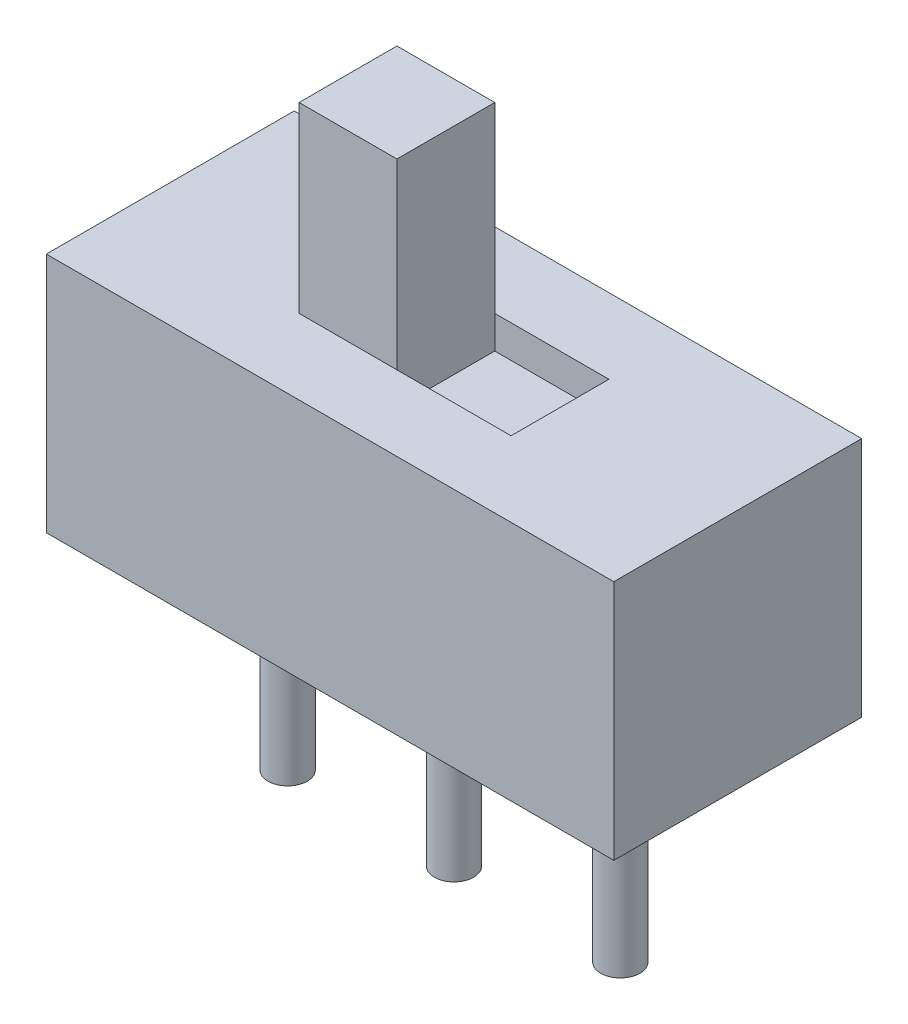
from build123d import *

# Parameters (mm, degrees)
ESQUISSE1_W             = 8.7
ESQUISSE1_H             = 3.7
BOSS_EXTRU_1_DEPTH      = 3.8
ESQUISSE2_W             = 3.25
ESQUISSE2_H             = 1.5
ENL_V_MAT_EXTRU_1_DEPTH = 0.5
ESQUISSE3_W             = 1.5
ESQUISSE3_H             = 1.5
BOSS_EXTRU_2_DEPTH      = 3.3
ESQUISSE4_R             = 0.3
BOSS_EXTRU_3_DEPTH      = 3.2


with BuildPart() as part:
    # Esquisse1 → Boss.-Extru.1 (new body)
    with BuildSketch(Plane.XY):
        with Locations((4.35, 1.85)):
            Rectangle(ESQUISSE1_W, ESQUISSE1_H)
    extrude(amount=BOSS_EXTRU_1_DEPTH)

    # Esquisse2 → Enlèv. mat.-Extru.1 (cut)
    with BuildSketch(Plane(origin=(0, 3.7, 0), x_dir=(1, 0, 0), z_dir=(0, 1, 0))):
        with Locations((4.35, -1.9)):
            Rectangle(ESQUISSE2_W, ESQUISSE2_H)
    extrude(amount=-ENL_V_MAT_EXTRU_1_DEPTH, mode=Mode.SUBTRACT)

    # Esquisse4 → Boss.-Extru.3 (add)
    with BuildSketch(Plane.XZ):
        with Locations((1.8, 1.9)):
            Circle(ESQUISSE4_R)
        with Locations((4.35, 1.9)):
            Circle(ESQUISSE4_R)
        with Locations((6.9, 1.9)):
            Circle(ESQUISSE4_R)
    extrude(amount=BOSS_EXTRU_3_DEPTH)


with BuildPart() as body_2:
    # Esquisse3 → Boss.-Extru.2 (new body)
    with BuildSketch(Plane(origin=(0, 3.2, 0), x_dir=(1, 0, 0), z_dir=(0, 1, 0))):
        with Locations((3.475, -1.9)):
            Rectangle(ESQUISSE3_W, ESQUISSE3_H)
    extrude(amount=BOSS_EXTRU_2_DEPTH)


solid = Compound([part.part, body_2.part])
